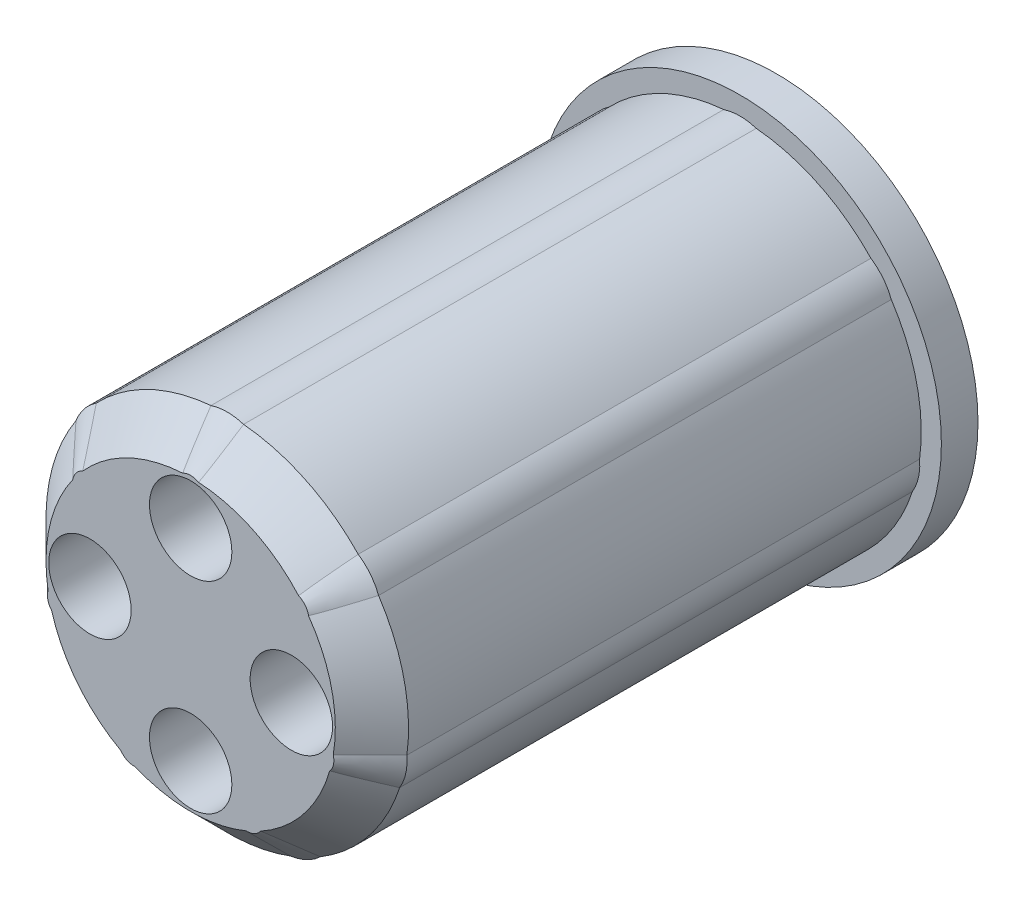
from build123d import *

# Parameters (mm, degrees)
AUFSATZ_LINEAR_AUSTRAGEN1_DEPTH      = 32
SKIZZE2_R                            = 11
AUFSATZ_LINEAR_AUSTRAGEN2_DEPTH      = 2
FASE1_SIZE                           = 2
SCHNITT_LINEAR_AUSTRAGEN1_DEPTH      = 34.793490586
SCHNITT_LINEAR_AUSTRAGEN1_DEPTH_BACK = 34.793490586
SKIZZE3_R                            = 2.25


with BuildPart() as part:
    # Skizze1 → Aufsatz-Linear austragen1 (new body)
    with BuildSketch(Plane.XY):
        with BuildLine():
            ThreePointArc((9.810830179, -1.325749297), (9.651786331, 2.202957246), (8.264031498, 5.451218525))
            ThreePointArc((8.264031498, 5.451218525), (7.818314825, 6.234898019), (7.153465102, 6.843824737))
            ThreePointArc((7.153465102, 6.843824737), (4.295449017, 8.919591792), (0.8906051, 9.859859155))
            ThreePointArc((0.8906051, 9.859859155), (0, 10), (-0.8906051, 9.859859155))
            ThreePointArc((-0.8906051, 9.859859155), (-4.295449017, 8.919591792), (-7.153465102, 6.843824737))
            ThreePointArc((-7.153465102, 6.843824737), (-7.818314825, 6.234898019), (-8.264031498, 5.451218525))
            ThreePointArc((-8.264031498, 5.451218525), (-9.651786331, 2.202957246), (-9.810830179, -1.325749297))
            ThreePointArc((-9.810830179, -1.325749297), (-9.749279122, -2.22520934), (-9.414473622, -3.062300839))
            ThreePointArc((-9.414473622, -3.062300839), (-7.740131676, -6.172549038), (-5.080440026, -8.497007069))
            ThreePointArc((-5.080440026, -8.497007069), (-4.338837391, -9.009688679), (-3.475625088, -9.269845212))
            ThreePointArc((-3.475625088, -9.269845212), (0, -9.9), (3.475625088, -9.269845212))
            ThreePointArc((3.475625088, -9.269845212), (4.338837391, -9.009688679), (5.080440026, -8.497007069))
            ThreePointArc((5.080440026, -8.497007069), (7.740131676, -6.172549038), (9.414473622, -3.062300839))
            ThreePointArc((9.414473622, -3.062300839), (9.749279122, -2.22520934), (9.810830179, -1.325749297))
        make_face()
    extrude(amount=AUFSATZ_LINEAR_AUSTRAGEN1_DEPTH)

    # Skizze2 → Aufsatz-Linear austragen2 (add)
    with BuildSketch(Plane.XY):
        Circle(SKIZZE2_R)
    extrude(amount=AUFSATZ_LINEAR_AUSTRAGEN2_DEPTH)

    # Fase1
    fase1_edges = [part.edges().sort_by_distance(p)[0] for p in [
        (9.749279122, -2.22520934, 32),
        (7.740131676, -6.172549038, 32),
        (4.338837391, -9.009688679, 32),
        (0, -9.9, 32),
        (-4.338837391, -9.009688679, 32),
        (-7.740131676, -6.172549038, 32),
        (-9.749279122, -2.22520934, 32),
        (-9.651786331, 2.202957246, 32),
        (-7.818314825, 6.234898019, 32),
        (-4.295449017, 8.919591792, 32),
        (0, 10, 32),
        (4.295449017, 8.919591792, 32),
        (7.818314825, 6.234898019, 32),
        (9.651786331, 2.202957246, 32),
    ]]
    chamfer(fase1_edges, length=FASE1_SIZE)

    # Skizze3 → Schnitt-Linear austragen1 (cut, two sides: drawn at the far end of the back side and taken through both)
    with BuildSketch(Plane.XY.offset(2).offset(-SCHNITT_LINEAR_AUSTRAGEN1_DEPTH_BACK)):
        with Locations((0, 5.5)):
            Circle(SKIZZE3_R)
        with Locations((5.5, 0)):
            Circle(SKIZZE3_R)
        with Locations((0, -5.5)):
            Circle(SKIZZE3_R)
        with Locations((-5.5, 0)):
            Circle(SKIZZE3_R)
    extrude(amount=SCHNITT_LINEAR_AUSTRAGEN1_DEPTH + SCHNITT_LINEAR_AUSTRAGEN1_DEPTH_BACK, mode=Mode.SUBTRACT)


solid = part.part
